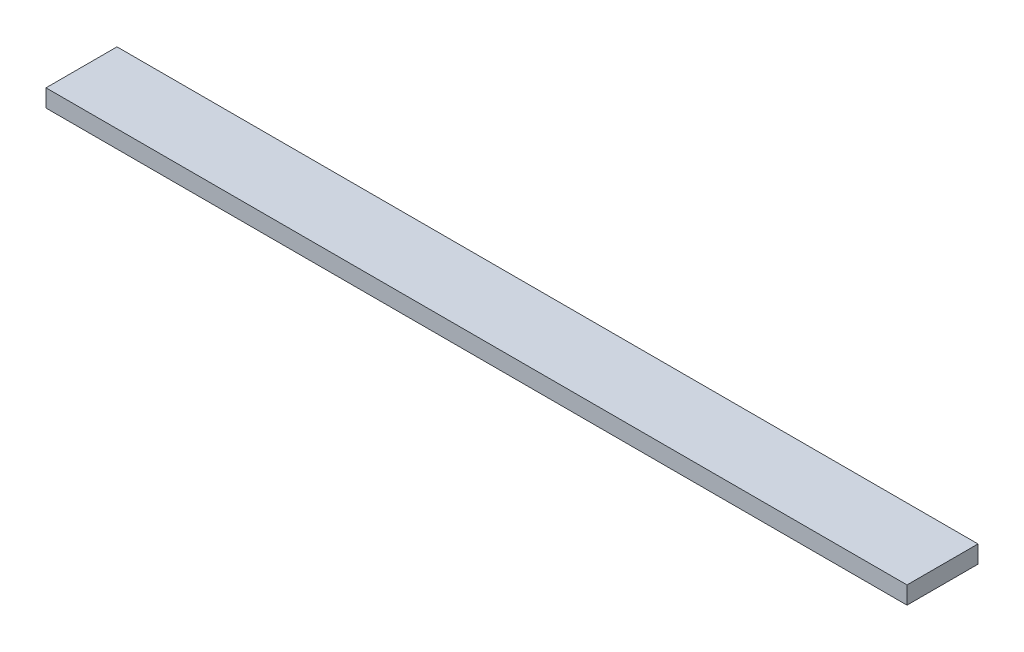
from build123d import *

# Parameters (mm, degrees)
SKETCH1_W           = 311
SKETCH1_H           = 25.64
BOSS_EXTRUDE1_DEPTH = 6.34


with BuildPart() as part:
    # Sketch1 → Boss-Extrude1 (new body)
    with BuildSketch(Plane(origin=(0, 0, 0), x_dir=(1, 0, 0), z_dir=(0, 1, 0))):
        Rectangle(SKETCH1_W, SKETCH1_H)
    extrude(amount=BOSS_EXTRUDE1_DEPTH)


solid = part.part
